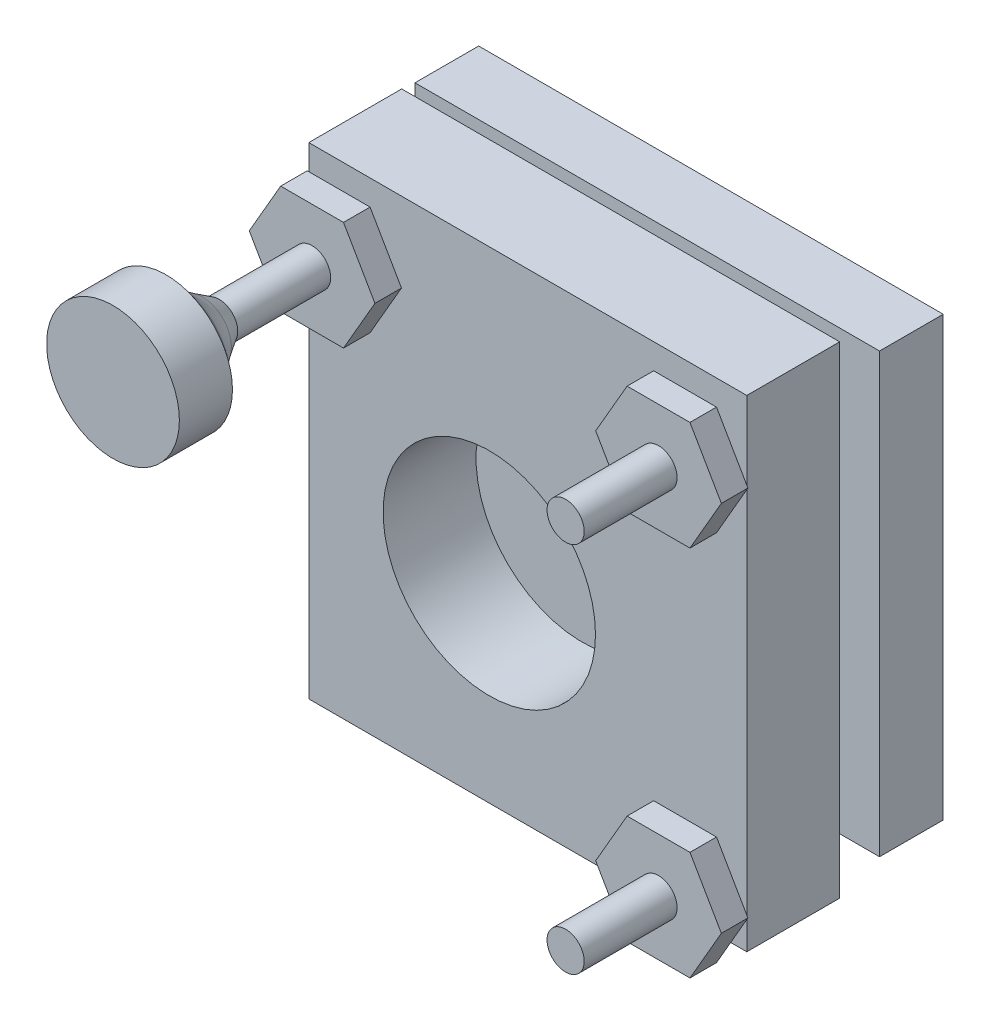
from build123d import *

# Parameters (mm, degrees)
CROQUIS1_W              = 33
CROQUIS1_H              = 7
SALIENTE_EXTRUIR1_DEPTH = 36.3
CROQUIS2_R              = 1.5
CORTAR_EXTRUIR1_DEPTH   = 5
CROQUIS3_R              = 8
CORTAR_EXTRUIR2_DEPTH   = 8
CROQUIS4_R              = 2.4
SALIENTE_EXTRUIR2_DEPTH = 1.2
SALIENTE_EXTRUIR3_DEPTH = 2
CROQUIS6_R              = 1.4
SALIENTE_EXTRUIR4_DEPTH = 7
CROQUIS9_W              = 35
CROQUIS9_H              = 33
SALIENTE_EXTRUIR5_DEPTH = 4.8
CROQUIS10_R             = 5.839659477
SALIENTE_EXTRUIR6_DEPTH = 1
CROQUIS11_R             = 14
SALIENTE_EXTRUIR7_DEPTH = 5
CROQUIS12_R             = 8
CORTAR_EXTRUIR3_DEPTH   = 1


with BuildPart() as part:
    # Croquis1 → Saliente-Extruir1 (new body)
    with BuildSketch(Plane(origin=(0, 0, 0), x_dir=(1, 0, 0), z_dir=(0, 1, 0))):
        Rectangle(CROQUIS1_W, CROQUIS1_H)
    extrude(amount=SALIENTE_EXTRUIR1_DEPTH)

    # Croquis2 → Cortar-Extruir1 (cut)
    with BuildSketch(Plane.XZ):
        with Locations((-6.8, 0)):
            Circle(CROQUIS2_R)
        with Locations((9.3, 0)):
            Circle(CROQUIS2_R)
    extrude(amount=-CORTAR_EXTRUIR1_DEPTH, mode=Mode.SUBTRACT)

    # Croquis3 → Cortar-Extruir2 (cut, through all)
    with BuildSketch(Plane.XY.offset(3.5)):
        with Locations((-2.9, 15)):
            Circle(CROQUIS3_R)
    extrude(amount=-CORTAR_EXTRUIR2_DEPTH, mode=Mode.SUBTRACT)

    # Croquis4 → Saliente-Extruir2 (add)
    with BuildSketch(Plane.XY.offset(3.5)):
        with Locations((-13.05, 31.5)):
            Circle(CROQUIS4_R)
        with Locations((13.05, 31.5)):
            Circle(CROQUIS4_R)
        with Locations((13.05, 3.45)):
            Circle(CROQUIS4_R)
    extrude(amount=SALIENTE_EXTRUIR2_DEPTH)

    # Croquis5 → Saliente-Extruir3 (add)
    with BuildSketch(Plane.XY.offset(4.7)):
        Polygon((-17.784272207, 31.5), (-15.417136104, 27.4), (-10.682863896, 27.4), (-8.315727793, 31.5), (-10.682863896, 35.6), (-15.417136104, 35.6), align=None)
        Polygon((17.784272207, 31.5), (15.417136104, 35.6), (10.682863896, 35.6), (8.315727793, 31.5), (10.682863896, 27.4), (15.417136104, 27.4), align=None)
        Polygon((17.784272207, 3.45), (15.417136104, 7.55), (10.682863896, 7.55), (8.315727793, 3.45), (10.682863896, -0.65), (15.417136104, -0.65), align=None)
    extrude(amount=SALIENTE_EXTRUIR3_DEPTH)

    # Croquis6 → Saliente-Extruir4 (add)
    with BuildSketch(Plane.XY.offset(6.7)):
        with Locations((-13.05, 31.5)):
            Circle(CROQUIS6_R)
        with Locations((13.05, 31.5)):
            Circle(CROQUIS6_R)
        with Locations((13.05, 3.45)):
            Circle(CROQUIS6_R)
    extrude(amount=SALIENTE_EXTRUIR4_DEPTH)

    # Croquis8 → Revolución1 (revolve)
    with BuildSketch(Plane.XZ.offset(-31.5)):
        with BuildLine():
            Line((-14.45, 13.7), (-15.232399286, 14.962983287))
            ThreePointArc((-15.232399286, 14.962983287), (-15.987008603, 15.967113671), (-16.908922521, 16.820218458))
            Line((-16.908922521, 16.820218458), (-18.05, 17.7))
            Line((-18.05, 17.7), (-18.05, 21.7))
            Line((-18.05, 21.7), (-13.05, 21.7))
            Line((-13.05, 21.7), (-13.05, 13.7))
            Line((-13.05, 13.7), (-14.45, 13.7))
        make_face()
    revolve(axis=Axis((-13.05, 31.5, 21.7), (0, 0, -1)))


with BuildPart() as body_2:
    # Croquis9 → Saliente-Extruir5 (new body)
    with BuildSketch(Plane(origin=(0, 0, -5.5), x_dir=(-1, 0, 0), z_dir=(0, 0, -1))):
        with Locations((0, 18.7)):
            Rectangle(CROQUIS9_W, CROQUIS9_H)
    extrude(amount=SALIENTE_EXTRUIR5_DEPTH)

    # Croquis10 → Saliente-Extruir6 (add)
    with BuildSketch(Plane(origin=(0, 0, -10.3), x_dir=(-1, 0, 0), z_dir=(0, 0, -1))):
        with Locations((2.9, 15)):
            Circle(CROQUIS10_R)
    extrude(amount=SALIENTE_EXTRUIR6_DEPTH)

    # Croquis11 → Saliente-Extruir7 (add)
    with BuildSketch(Plane(origin=(0, 0, -11.3), x_dir=(-1, 0, 0), z_dir=(0, 0, -1))):
        with Locations((2.9, 15)):
            Circle(CROQUIS11_R)
    extrude(amount=SALIENTE_EXTRUIR7_DEPTH)

    # Croquis12 → Cortar-Extruir3 (cut)
    with BuildSketch(Plane(origin=(0, 0, -16.3), x_dir=(-1, 0, 0), z_dir=(0, 0, -1))):
        with Locations((2.9, 15)):
            Circle(CROQUIS12_R)
    extrude(amount=-CORTAR_EXTRUIR3_DEPTH, mode=Mode.SUBTRACT)


solid = Compound([part.part, body_2.part])
